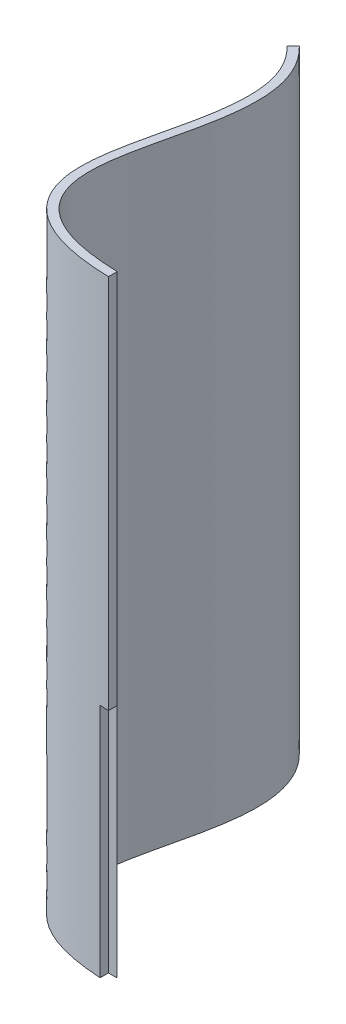
from build123d import *

# Parameters (mm, degrees)
CROQUIS1_W              = 30
CROQUIS1_H              = 80
SALIENTE_EXTRUIR1_DEPTH = 140
CORTAR_EXTRUIR1_DEPTH   = 141
CROQUIS3_W              = 2.000851936
CROQUIS3_H              = 54
CORTAR_EXTRUIR2_DEPTH   = 2


with BuildPart() as part:
    # Croquis1 → Saliente-Extruir1 (new body)
    with BuildSketch(Plane(origin=(0, 0, 0), x_dir=(1, 0, 0), z_dir=(0, 1, 0))):
        with Locations((-32.289164152, -33.781461754)):
            Rectangle(CROQUIS1_W, CROQUIS1_H)
    extrude(amount=SALIENTE_EXTRUIR1_DEPTH)

    # Croquis2 → Cortar-Extruir1 (cut, through all)
    with BuildSketch(Plane(origin=(0, 140, 0), x_dir=(1, 0, 0), z_dir=(0, 1, 0))):
        with BuildLine():
            Line((-47.289164152, -73.781461754), (-17.289164152, -73.781461754))
            add(Edge.make_bspline(
                [(-17.289164152, -73.781461754), (-18.028790745, -73.760167812), (-19.536736039, -73.694334347), (-21.619201378, -73.534198465), (-23.60026042, -73.310865821), (-26.085305832, -72.929731587), (-28.923554013, -72.295740091), (-31.925616811, -71.278451947), (-34.556591531, -69.988486168), (-37.556020515, -67.907598696), (-40.340850878, -64.61069966), (-42.041141092, -59.98828157), (-42.46994198, -55.1343895), (-42.064232899, -50.118165725), (-40.821359448, -43.247598034), (-39.046239792, -36.169847805), (-37.670394081, -29.215175232), (-37.054360796, -24.173452889), (-37.05194859, -19.429814206), (-37.692700661, -15.813013959), (-38.661503867, -13.133702332), (-39.638797415, -11.223052021), (-40.693571404, -9.698906715), (-41.695258282, -8.524055184), (-42.26504447, -7.938852239), (-42.554999929, -7.659734641)],
                knots=[0, 0, 0, 0, 0.015252929, 0.030505859, 0.045758788, 0.061011718, 0.091517577, 0.122023436, 0.152529294, 0.183035153, 0.244046871, 0.305058589, 0.366070307, 0.427082025, 0.488093742, 0.610117178, 0.671128896, 0.732140613, 0.793152331, 0.854164049, 0.884669908, 0.915175767, 0.945681626, 0.960934555, 0.976187485, 0.976187485, 0.976187485, 0.976187485], degree=3))
            Line((-42.554999929, -7.659734641), (-41.167971247, -6.218848999))
            add(Edge.make_bspline(
                [(-17.289164149, -71.780609724), (-17.989897624, -71.759867801), (-19.437647711, -71.696034282), (-21.431834226, -71.542554366), (-23.339287673, -71.327444133), (-25.713389965, -70.963135168), (-28.394980997, -70.36292597), (-31.171968634, -69.419957516), (-33.551385324, -68.250670285), (-36.187417425, -66.417246395), (-38.572343047, -63.588661041), (-40.058368199, -59.579977963), (-40.461410262, -55.159116811), (-40.081165503, -50.399485353), (-38.873478235, -43.707477121), (-37.101064693, -36.637590027), (-35.696305064, -29.546732583), (-35.055039174, -24.316937629), (-35.047218805, -19.281220812), (-35.742523876, -15.323177806), (-36.820958485, -12.337295039), (-37.918383572, -10.191651316), (-39.099645947, -8.484992992), (-40.218055479, -7.173641955), (-40.847051558, -6.527773455), (-41.167971247, -6.218848999)],
                knots=[0.000406696, 0.000406696, 0.000406696, 0.000406696, 0.015252929, 0.030505859, 0.045758788, 0.061011718, 0.091517577, 0.122023436, 0.152529294, 0.183035153, 0.244046871, 0.305058589, 0.366070307, 0.427082025, 0.488093742, 0.610117178, 0.671128896, 0.732140613, 0.793152331, 0.854164049, 0.884669908, 0.915175767, 0.945681626, 0.960934555, 0.976187485, 0.976187485, 0.976187485, 0.976187485], degree=3))
            Line((-17.289164152, -71.780609818), (-17.289164152, 6.218538246))
            Line((-17.289164152, 6.218538246), (-47.289164152, 6.218538246))
            Line((-47.289164152, 6.218538246), (-47.289164152, -73.781461754))
        make_face()
    extrude(amount=-CORTAR_EXTRUIR1_DEPTH, mode=Mode.SUBTRACT)

    # Croquis3 → Cortar-Extruir2 (cut)
    with BuildSketch(Plane(origin=(-17.289164152, 0, 0), x_dir=(0, 0, -1), z_dir=(1, 0, 0))):
        with Locations((-72.781035786, 27)):
            Rectangle(CROQUIS3_W, CROQUIS3_H)
    extrude(amount=-CORTAR_EXTRUIR2_DEPTH, mode=Mode.SUBTRACT)


solid = part.part
